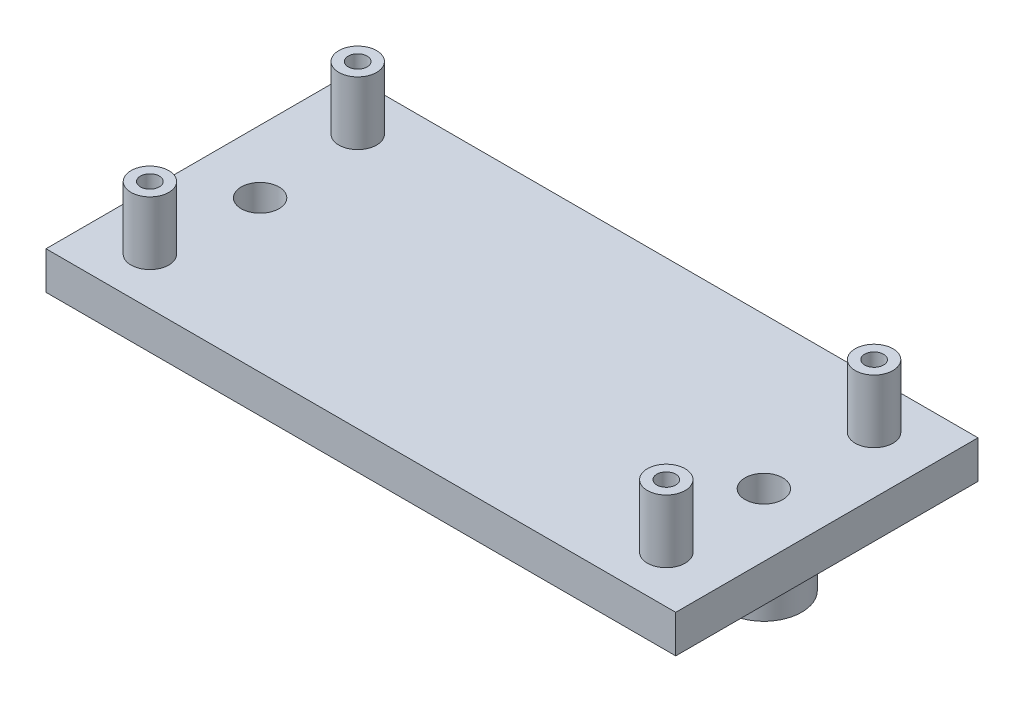
from build123d import *

# Parameters (mm, degrees)
SKETCH1_W           = 50
SKETCH1_H           = 24
BOSS_EXTRUDE1_DEPTH = 3
SKETCH2_R           = 3
SKETCH2_R_2         = 1.5
BOSS_EXTRUDE2_DEPTH = 4
SKETCH3_R           = 0.9
CUT_EXTRUDE1_DEPTH  = 10
SKETCH4_R           = 1.5
SKETCH4_R_2         = 0.75
BOSS_EXTRUDE3_DEPTH = 5
SKETCH5_R           = 1.5
CUT_EXTRUDE2_DEPTH  = 10


with BuildPart() as part:
    # Sketch1 → Boss-Extrude1 (new body)
    with BuildSketch(Plane(origin=(0, 0, 0), x_dir=(1, 0, 0), z_dir=(0, 1, 0))):
        with Locations((25, -12)):
            Rectangle(SKETCH1_W, SKETCH1_H)
    extrude(amount=BOSS_EXTRUDE1_DEPTH)

    # Sketch2 → Boss-Extrude2 (add)
    with BuildSketch(Plane.XZ):
        with Locations((5, 12)):
            Circle(SKETCH2_R)
        with Locations((5, 12)):
            Circle(SKETCH2_R_2, mode=Mode.SUBTRACT)
        with Locations((45, 12)):
            Circle(SKETCH2_R)
        with Locations((45, 12)):
            Circle(SKETCH2_R_2, mode=Mode.SUBTRACT)
    extrude(amount=BOSS_EXTRUDE2_DEPTH)

    # Sketch3 → Cut-Extrude1 (cut)
    with BuildSketch(Plane(origin=(0, 3, 0), x_dir=(1, 0, 0), z_dir=(0, 1, 0))):
        with Locations((4.5, -3.75)):
            Circle(SKETCH3_R)
        with Locations((45.5, -3.75)):
            Circle(SKETCH3_R)
        with Locations((45.5, -20.25)):
            Circle(SKETCH3_R)
        with Locations((4.5, -20.25)):
            Circle(SKETCH3_R)
    extrude(amount=-CUT_EXTRUDE1_DEPTH, mode=Mode.SUBTRACT)

    # Sketch4 → Boss-Extrude3 (add)
    with BuildSketch(Plane(origin=(0, 3, 0), x_dir=(1, 0, 0), z_dir=(0, 1, 0))):
        with Locations((4.5, -3.75)):
            Circle(SKETCH4_R)
        with Locations((4.5, -3.75)):
            Circle(SKETCH4_R_2, mode=Mode.SUBTRACT)
        with Locations((45.5, -3.75)):
            Circle(SKETCH4_R)
        with Locations((45.5, -3.75)):
            Circle(SKETCH4_R_2, mode=Mode.SUBTRACT)
        with Locations((4.5, -20.25)):
            Circle(SKETCH4_R)
        with Locations((4.5, -20.25)):
            Circle(SKETCH4_R_2, mode=Mode.SUBTRACT)
        with Locations((45.5, -20.25)):
            Circle(SKETCH4_R)
        with Locations((45.5, -20.25)):
            Circle(SKETCH4_R_2, mode=Mode.SUBTRACT)
    extrude(amount=BOSS_EXTRUDE3_DEPTH)

    # Sketch5 → Cut-Extrude2 (cut)
    with BuildSketch(Plane.XZ):
        with Locations((5, 12)):
            Circle(SKETCH5_R)
        with Locations((45, 12)):
            Circle(SKETCH5_R)
    extrude(amount=-CUT_EXTRUDE2_DEPTH, mode=Mode.SUBTRACT)


solid = part.part
